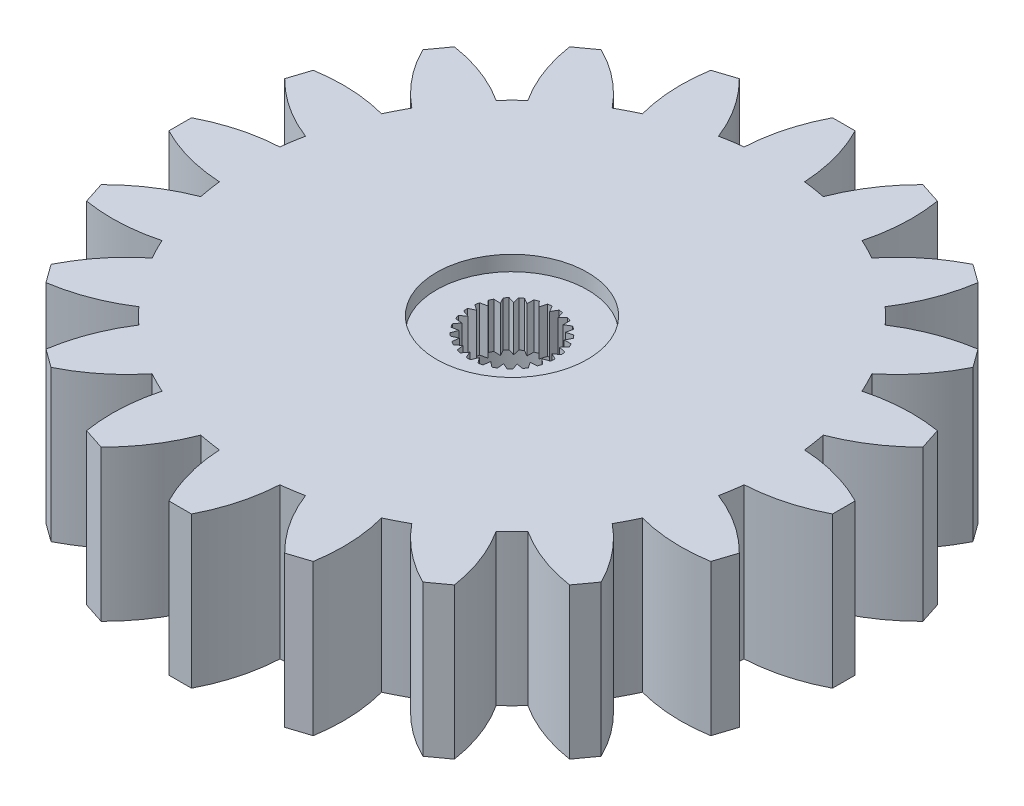
from build123d import *

# Parameters (mm, degrees)
SKETCH2_R           = 17.5
BOSS_EXTRUDE1_DEPTH = 10
BOSS_EXTRUDE2_DEPTH = 10
CIRPATTERN1_COUNT   = 20
CUT_EXTRUDE2_START  = 10
CUT_EXTRUDE2_DEPTH  = 4
SKETCH3_R           = 5
CUT_EXTRUDE3_DEPTH  = 6
SKETCH4_R           = 5
CUT_EXTRUDE4_DEPTH  = 1


with BuildPart() as part:
    # Sketch2 → Boss-Extrude1 (new body)
    with BuildSketch(Plane(origin=(0, 0, 0), x_dir=(1, 0, 0), z_dir=(0, 1, 0))):
        with Locations(Location((0, 0, 0), (0, 0, 270))):
            Circle(SKETCH2_R)
    extrude(amount=BOSS_EXTRUDE1_DEPTH)

    # Sketch2_4 → Boss-Extrude2 (add)
    with BuildSketch(Plane(origin=(0, 0, 0), x_dir=(1, 0, 0), z_dir=(0, 1, 0))):
        with BuildLine():
            Line((0.75, 21.987212193), (-0.75, 21.987212193))
            ThreePointArc((-0.75, 21.987212193), (-1.621188566, 19.753147252), (-2, 17.385338651))
            ThreePointArc((-2, 17.385338651), (0, 17.5), (2, 17.385338651))
            ThreePointArc((2, 17.385338651), (1.621188566, 19.753147252), (0.75, 21.987212193))
        make_face()
    boss_extrude2 = extrude(amount=BOSS_EXTRUDE2_DEPTH)

    # CirPattern1: Boss-Extrude2 ×20 about axis
    cirpattern1_axis = Axis((0, 0, 0), (0, 1, 0))
    for i in range(1, CIRPATTERN1_COUNT):
        add(boss_extrude2.rotate(cirpattern1_axis, i * 360 / CIRPATTERN1_COUNT))

    # Sketch2_7 → Cut-Extrude2 (cut)
    with BuildSketch(Plane(origin=(0, 0, 0), x_dir=(1, 0, 0), z_dir=(0, 1, 0)).offset(CUT_EXTRUDE2_START)):
        with BuildLine():
            Line((0, 2.5), (-0.225854656, 2.891191739))
            ThreePointArc((-0.225854656, 2.891191739), (-0.363466377, 2.877132634), (-0.500251131, 2.856527403))
            Line((-0.500251131, 2.856527403), (-0.621724718, 2.421457903))
            Line((-0.621724718, 2.421457903), (-0.937769164, 2.744191865))
            ThreePointArc((-0.937769164, 2.744191865), (-1.067561203, 2.696351809), (-1.194924299, 2.642376945))
            Line((-1.194924299, 2.642376945), (-1.204384185, 2.1907667))
            Line((-1.204384185, 2.1907667), (-1.590760187, 2.424764324))
            ThreePointArc((-1.590760187, 2.424764324), (-1.704577232, 2.346149284), (-1.814515979, 2.262196225))
            Line((-1.814515979, 2.262196225), (-1.711367765, 1.822421569))
            Line((-1.711367765, 1.822421569), (-2.143797897, 1.952979923))
            ThreePointArc((-2.143797897, 1.952979923), (-2.234488404, 1.84852957), (-2.320094947, 1.739873397))
            Line((-2.320094947, 1.739873397), (-2.110819814, 1.339566987))
            Line((-2.110819814, 1.339566987), (-2.5621329, 1.35848261))
            ThreePointArc((-2.5621329, 1.35848261), (-2.623998452, 1.234759946), (-2.679893817, 1.108227924))
            Line((-2.679893817, 1.108227924), (-2.377641291, 0.772542486))
            Line((-2.377641291, 0.772542486), (-2.819479671, 0.678626839))
            ThreePointArc((-2.819479671, 0.678626839), (-2.848633027, 0.543405812), (-2.871305102, 0.406948415))
            Line((-2.871305102, 0.406948415), (-2.495066821, 0.156976299))
            Line((-2.495066821, 0.156976299), (-2.899668164, -0.043869552))
            ThreePointArc((-2.899668164, -0.043869552), (-2.894277512, -0.182092507), (-2.882301727, -0.31990116))
            Line((-2.882301727, -0.31990116), (-2.455718127, -0.468453286))
            Line((-2.455718127, -0.468453286), (-2.797659843, -0.763609458))
            ThreePointArc((-2.797659843, -0.763609458), (-2.758063897, -0.896149284), (-2.712192735, -1.026650168))
            Line((-2.712192735, -1.026650168), (-2.262067631, -1.064448229))
            Line((-2.262067631, -1.064448229), (-2.519864264, -1.435368973))
            ThreePointArc((-2.519864264, -1.435368973), (-2.448550984, -1.553897705), (-2.371666699, -1.66889097))
            Line((-2.371666699, -1.66889097), (-1.926283107, -1.593559974))
            Line((-1.926283107, -1.593559974), (-2.083736347, -2.016938977))
            ThreePointArc((-2.083736347, -2.016938977), (-1.985186607, -2.11400902), (-1.882120121, -2.206269215))
            Line((-1.882120121, -2.206269215), (-1.469463131, -2.022542486))
            Line((-1.469463131, -2.022542486), (-1.516679611, -2.471777287))
            ThreePointArc((-1.516679611, -2.471777287), (-1.397085655, -2.541289372), (-1.274313014, -2.605019451))
            Line((-1.274313014, -2.605019451), (-0.920311382, -2.324441215))
            Line((-0.920311382, -2.324441215), (-0.854324317, -2.77130474))
            ThreePointArc((-0.854324317, -2.77130474), (-0.721200673, -2.808891167), (-0.586436134, -2.840086735))
            Line((-0.586436134, -2.840086735), (-0.313333084, -2.480286753))
            Line((-0.313333084, -2.480286753), (-0.138288685, -2.896700923))
            ThreePointArc((-0.138288685, -2.896700923), (0, -2.9), (0.138288685, -2.896700923))
            Line((0.138288685, -2.896700923), (0.313333084, -2.480286753))
            Line((0.313333084, -2.480286753), (0.586436134, -2.840086735))
            ThreePointArc((0.586436134, -2.840086735), (0.721200673, -2.808891167), (0.854324317, -2.77130474))
            Line((0.854324317, -2.77130474), (0.920311382, -2.324441215))
            Line((0.920311382, -2.324441215), (1.274313014, -2.605019451))
            ThreePointArc((1.274313014, -2.605019451), (1.397085655, -2.541289372), (1.516679611, -2.471777287))
            Line((1.516679611, -2.471777287), (1.469463131, -2.022542486))
            Line((1.469463131, -2.022542486), (1.882120121, -2.206269215))
            ThreePointArc((1.882120121, -2.206269215), (1.985186607, -2.11400902), (2.083736347, -2.016938977))
            Line((2.083736347, -2.016938977), (1.926283107, -1.593559974))
            Line((1.926283107, -1.593559974), (2.371666699, -1.66889097))
            ThreePointArc((2.371666699, -1.66889097), (2.448550984, -1.553897705), (2.519864264, -1.435368973))
            Line((2.519864264, -1.435368973), (2.262067631, -1.064448229))
            Line((2.262067631, -1.064448229), (2.712192735, -1.026650168))
            ThreePointArc((2.712192735, -1.026650168), (2.758063897, -0.896149284), (2.797659843, -0.763609458))
            Line((2.797659843, -0.763609458), (2.455718127, -0.468453286))
            Line((2.455718127, -0.468453286), (2.882301727, -0.31990116))
            ThreePointArc((2.882301727, -0.31990116), (2.894277512, -0.182092507), (2.899668164, -0.043869552))
            Line((2.899668164, -0.043869552), (2.495066821, 0.156976299))
            Line((2.495066821, 0.156976299), (2.871305102, 0.406948415))
            ThreePointArc((2.871305102, 0.406948415), (2.848633027, 0.543405812), (2.819479671, 0.678626839))
            Line((2.819479671, 0.678626839), (2.377641291, 0.772542486))
            Line((2.377641291, 0.772542486), (2.679893817, 1.108227924))
            ThreePointArc((2.679893817, 1.108227924), (2.623998452, 1.234759946), (2.5621329, 1.35848261))
            Line((2.5621329, 1.35848261), (2.110819814, 1.339566987))
            Line((2.110819814, 1.339566987), (2.320094947, 1.739873397))
            ThreePointArc((2.320094947, 1.739873397), (2.234488404, 1.84852957), (2.143797897, 1.952979923))
            Line((2.143797897, 1.952979923), (1.711367765, 1.822421569))
            Line((1.711367765, 1.822421569), (1.814515979, 2.262196225))
            ThreePointArc((1.814515979, 2.262196225), (1.704577232, 2.346149284), (1.590760187, 2.424764324))
            Line((1.590760187, 2.424764324), (1.204384185, 2.1907667))
            Line((1.204384185, 2.1907667), (1.194924299, 2.642376945))
            ThreePointArc((1.194924299, 2.642376945), (1.067561203, 2.696351809), (0.937769164, 2.744191865))
            Line((0.937769164, 2.744191865), (0.621724718, 2.421457903))
            Line((0.621724718, 2.421457903), (0.500251131, 2.856527403))
            ThreePointArc((0.500251131, 2.856527403), (0.363466377, 2.877132634), (0.225854656, 2.891191739))
            Line((0.225854656, 2.891191739), (0, 2.5))
        make_face()
    extrude(amount=-CUT_EXTRUDE2_DEPTH, mode=Mode.SUBTRACT)

    # Sketch3 → Cut-Extrude3 (cut)
    with BuildSketch(Plane.XZ):
        with Locations(Location((0, 0, 0), (0, 0, 270))):
            Circle(SKETCH3_R)
    extrude(amount=-CUT_EXTRUDE3_DEPTH, mode=Mode.SUBTRACT)

    # Sketch4 → Cut-Extrude4 (cut)
    with BuildSketch(Plane(origin=(0, 10, 0), x_dir=(1, 0, 0), z_dir=(0, 1, 0))):
        with Locations(Location((0, 0, 0), (0, 0, 90))):
            Circle(SKETCH4_R)
    extrude(amount=-CUT_EXTRUDE4_DEPTH, mode=Mode.SUBTRACT)


solid = part.part
